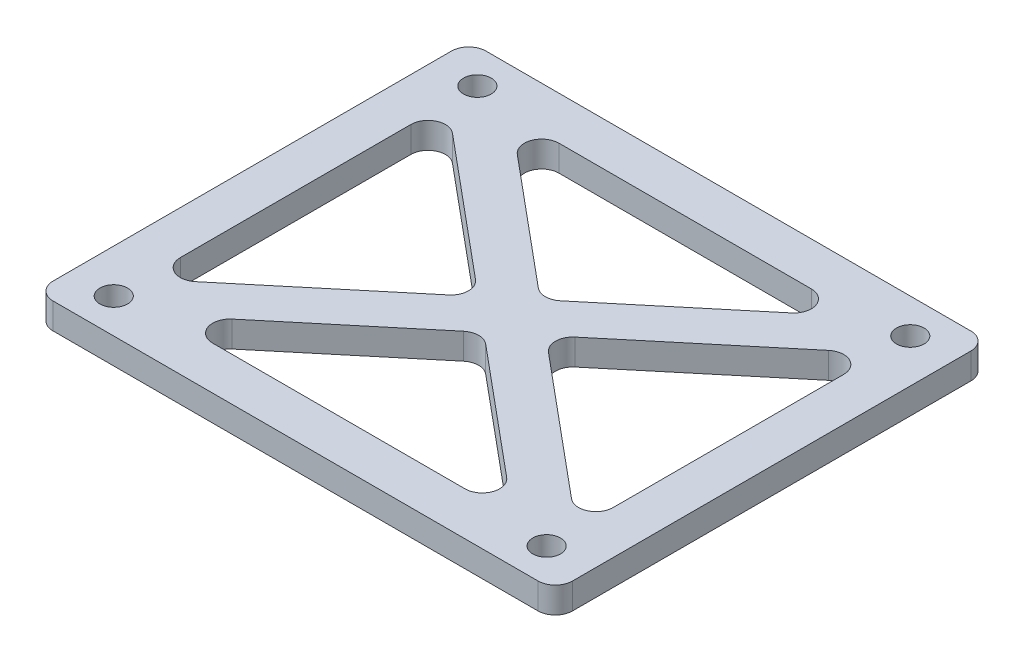
from build123d import *

# Parameters (mm, degrees)
SKETCH_1_W      = 60
SKETCH_1_H      = 50
SKETCH_1_R      = 1.6
EXTRUDE_1_DEPTH = 3
FILLET_1_R      = 2
FILLET_2_R      = 2


with BuildPart() as part:
    # 草图1 → 凸台-拉伸1 (new body)
    with BuildSketch(Plane(origin=(0, 0, 0), x_dir=(1, 0, 0), z_dir=(0, 1, 0))):
        Rectangle(SKETCH_1_W, SKETCH_1_H)
        with Locations((-25, 21)):
            Circle(SKETCH_1_R, mode=Mode.SUBTRACT)
        with Locations((25, 21)):
            Circle(SKETCH_1_R, mode=Mode.SUBTRACT)
        with Locations((25, -21)):
            Circle(SKETCH_1_R, mode=Mode.SUBTRACT)
        with Locations((-25, -21)):
            Circle(SKETCH_1_R, mode=Mode.SUBTRACT)
        Polygon((-25, 17.579062635), (-3.905124838, 0), (-25, -17.579062635), align=None, mode=Mode.SUBTRACT)
        Polygon((25, 17.579062635), (25, -17.579062635), (3.905124838, 0), align=None, mode=Mode.SUBTRACT)
        Polygon((-20.094875162, -20), (0, -3.254270698), (20.094875162, -20), align=None, mode=Mode.SUBTRACT)
        Polygon((20.094875162, 20), (0, 3.254270698), (-20.094875162, 20), align=None, mode=Mode.SUBTRACT)
    extrude(amount=EXTRUDE_1_DEPTH)

    # 圆角1
    fillet_1_edges = [part.edges().sort_by_distance(p)[0] for p in [
        (30, 1.5, 25),
        (-30, 1.5, 25),
        (-30, 1.5, -25),
        (30, 1.5, -25),
    ]]
    fillet(fillet_1_edges, radius=FILLET_1_R)

    # 圆角2
    fillet_2_edges = [part.edges().sort_by_distance(p)[0] for p in [
        (-25, 1.5, -17.579062635),
        (-25, 1.5, 17.579062635),
        (-3.905124838, 1.5, 0),
        (-20.094875162, 1.5, 20),
        (20.094875162, 1.5, 20),
        (0, 1.5, 3.254270698),
        (3.905124838, 1.5, 0),
        (25, 1.5, 17.579062635),
        (25, 1.5, -17.579062635),
        (20.094875162, 1.5, -20),
        (-20.094875162, 1.5, -20),
        (0, 1.5, -3.254270698),
    ]]
    fillet(fillet_2_edges, radius=FILLET_2_R)


solid = part.part
